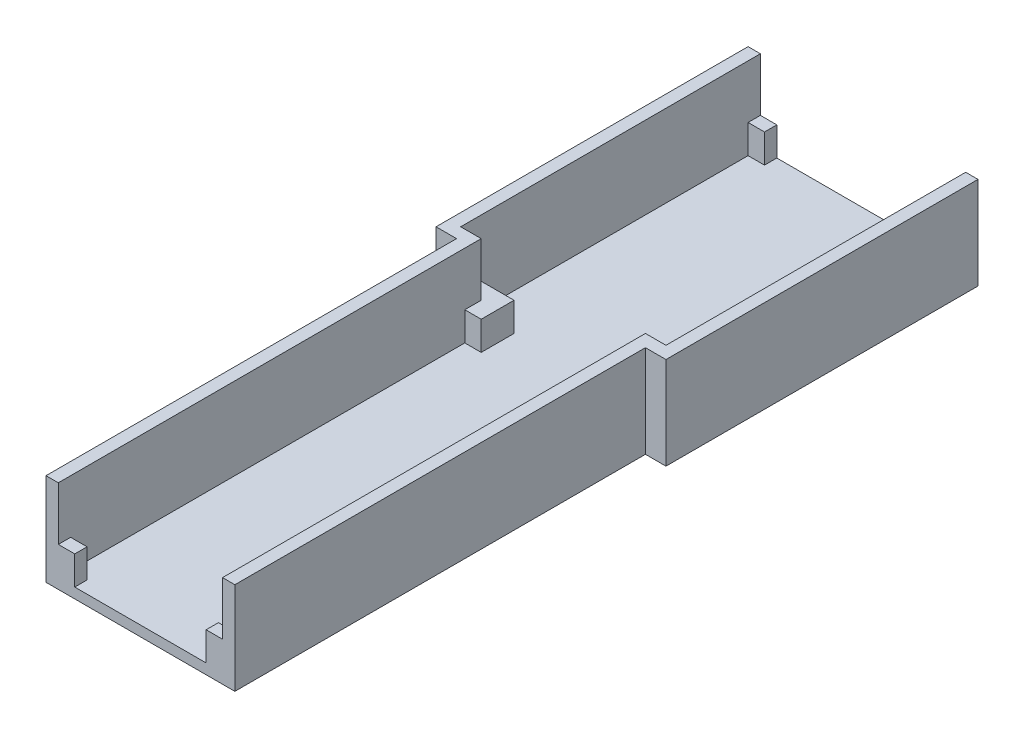
from build123d import *

# Parameters (mm, degrees)
SKETCH1_W           = 46
SKETCH1_H           = 103
SKETCH1_W_2         = 56
SKETCH1_H_2         = 73
BOSS_EXTRUDE2_DEPTH = 2.5
BOSS_EXTRUDE3_DEPTH = 20
SKETCH4_W           = 3
SKETCH4_H           = 22.5
BOSS_EXTRUDE4_DEPTH = 5
SKETCH7_W           = 3
SKETCH7_H           = 22.5
BOSS_EXTRUDE5_DEPTH = 5
SKETCH8_W           = 4
SKETCH8_H           = 3
CUT_EXTRUDE1_DEPTH  = 13
SKETCH9_W           = 42
SKETCH9_H           = 3
CUT_EXTRUDE2_DEPTH  = 20
SKETCH10_W          = 32
SKETCH10_H          = 3
CUT_EXTRUDE3_DEPTH  = 20
SKETCH11_W          = 4
SKETCH11_H          = 4
BOSS_EXTRUDE6_DEPTH = 7


with BuildPart() as part:
    # Sketch1 → Boss-Extrude2 (new body)
    with BuildSketch(Plane(origin=(0, 0, 0), x_dir=(1, 0, 0), z_dir=(0, 1, 0))):
        with Locations((49.995495495, -98.63963964)):
            Rectangle(SKETCH1_W, SKETCH1_H)
        with Locations((49.995495495, -10.63963964)):
            Rectangle(SKETCH1_W_2, SKETCH1_H_2)
    extrude(amount=BOSS_EXTRUDE2_DEPTH)

    # Sketch3 → Boss-Extrude3 (add)
    with BuildSketch(Plane(origin=(0, 2.5, 0), x_dir=(1, 0, 0), z_dir=(0, 1, 0))):
        Polygon((24.995495495, -47.13963964), (24.995495495, 22.86036036), (74.995495495, 22.86036036), (74.995495495, -47.13963964), (77.995495495, -47.13963964), (77.995495495, 25.86036036), (21.995495495, 25.86036036), (21.995495495, -47.13963964), align=None)
        Polygon((29.995495495, -47.13963964), (26.995495495, -47.13963964), (26.995495495, -150.13963964), (72.995495495, -150.13963964), (72.995495495, -47.13963964), (69.995495495, -47.13963964), (69.995495495, -147.13963964), (29.995495495, -147.13963964), align=None)
    extrude(amount=BOSS_EXTRUDE3_DEPTH)

    # Sketch4 → Boss-Extrude4 (add)
    with BuildSketch(Plane.ZY.offset(-26.995495495)):
        with Locations((48.63963964, 11.25)):
            Rectangle(SKETCH4_W, SKETCH4_H)
    extrude(amount=BOSS_EXTRUDE4_DEPTH)

    # Sketch7 → Boss-Extrude5 (add)
    with BuildSketch(Plane(origin=(72.995495495, 0, 0), x_dir=(0, 0, -1), z_dir=(1, 0, 0))):
        with Locations((-48.63963964, 11.25)):
            Rectangle(SKETCH7_W, SKETCH7_H)
    extrude(amount=BOSS_EXTRUDE5_DEPTH)

    # Sketch8 → Cut-Extrude1 (cut)
    with BuildSketch(Plane(origin=(0, 22.5, 0), x_dir=(1, 0, 0), z_dir=(0, 1, 0))):
        with Locations((26.995495495, 24.36036036)):
            Rectangle(SKETCH8_W, SKETCH8_H)
        with Locations((72.995495495, 24.36036036)):
            Rectangle(SKETCH8_W, SKETCH8_H)
        with Locations((67.995495495, -148.63963964)):
            Rectangle(SKETCH8_W, SKETCH8_H)
        with Locations((31.995495495, -148.63963964)):
            Rectangle(SKETCH8_W, SKETCH8_H)
    extrude(amount=-CUT_EXTRUDE1_DEPTH, mode=Mode.SUBTRACT)

    # Sketch9 → Cut-Extrude2 (cut)
    with BuildSketch(Plane(origin=(0, 22.5, 0), x_dir=(1, 0, 0), z_dir=(0, 1, 0))):
        with Locations((49.995495495, 24.36036036)):
            Rectangle(SKETCH9_W, SKETCH9_H)
    extrude(amount=-CUT_EXTRUDE2_DEPTH, mode=Mode.SUBTRACT)

    # Sketch10 → Cut-Extrude3 (cut)
    with BuildSketch(Plane(origin=(0, 22.5, 0), x_dir=(1, 0, 0), z_dir=(0, 1, 0))):
        with Locations((49.995495495, -148.63963964)):
            Rectangle(SKETCH10_W, SKETCH10_H)
    extrude(amount=-CUT_EXTRUDE3_DEPTH, mode=Mode.SUBTRACT)

    # Sketch11 → Boss-Extrude6 (add)
    with BuildSketch(Plane(origin=(0, 2.5, 0), x_dir=(1, 0, 0), z_dir=(0, 1, 0))):
        with Locations((31.995495495, -49.13963964)):
            Rectangle(SKETCH11_W, SKETCH11_H)
        Polygon((24.995495495, -47.13963964), (29.995495495, -47.13963964), (33.995495495, -47.13963964), (33.995495495, -43.13963964), (24.995495495, -43.13963964), align=None)
        Polygon((65.995495495, -47.13963964), (69.995495495, -47.13963964), (74.995495495, -47.13963964), (74.995495495, -43.13963964), (65.995495495, -43.13963964), align=None)
        with Locations((67.995495495, -49.13963964)):
            Rectangle(SKETCH11_W, SKETCH11_H)
    extrude(amount=BOSS_EXTRUDE6_DEPTH)


solid = part.part
